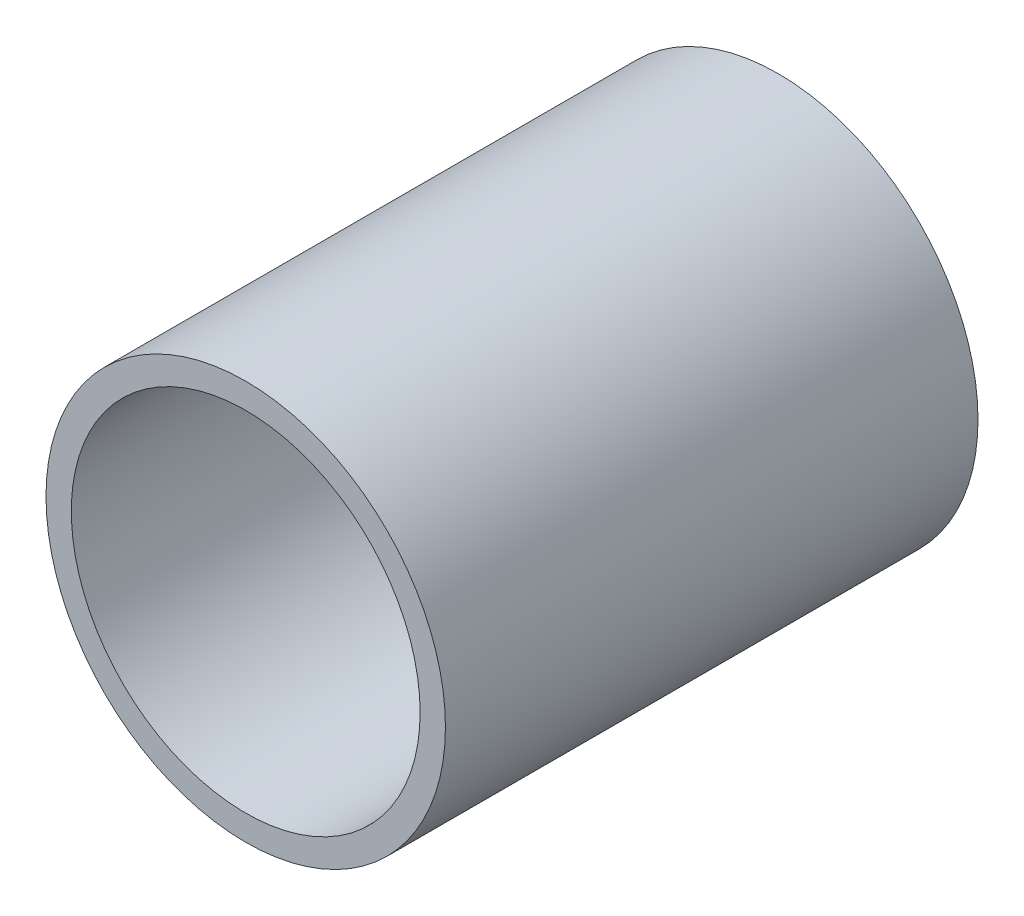
from build123d import *

# Parameters (mm, degrees)
SKETCH1_R      = 19.05
SKETCH1_R_2    = 16.637
EXTRUDE1_DEPTH = 50.8


with BuildPart() as part:
    # Sketch1 → Extrude1 (new body)
    with BuildSketch(Plane.XY):
        Circle(SKETCH1_R)
        Circle(SKETCH1_R_2, mode=Mode.SUBTRACT)
    extrude(amount=EXTRUDE1_DEPTH)


solid = part.part
